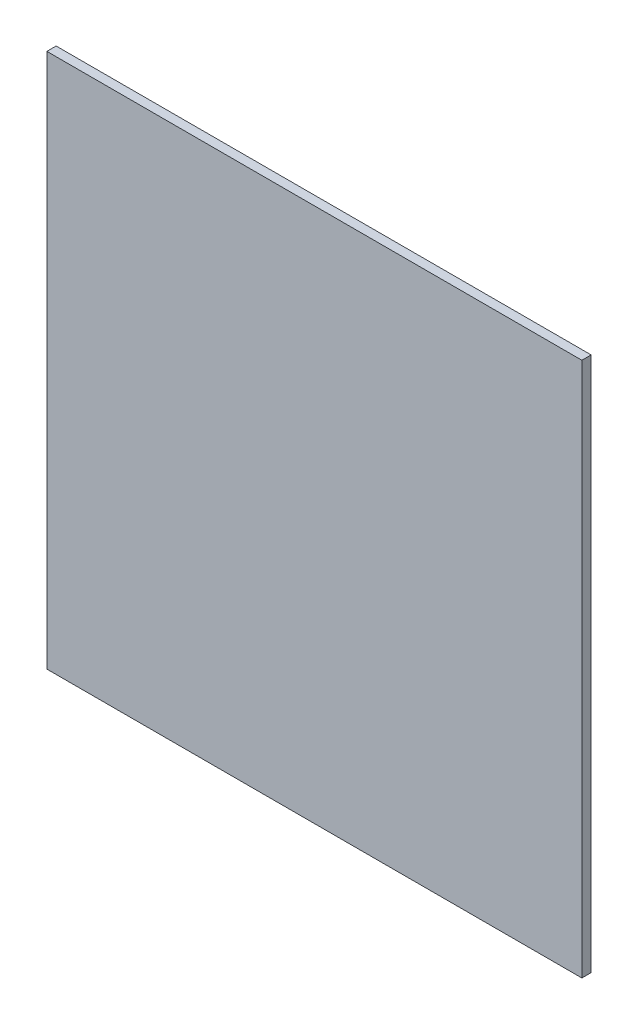
from build123d import *

# Parameters (mm, degrees)
SKETCH1_W           = 1100
SKETCH1_H           = 1100
BOSS_EXTRUDE1_DEPTH = 19.05


with BuildPart() as part:
    # Sketch1 → Boss-Extrude1 (new body)
    with BuildSketch(Plane.XY):
        Rectangle(SKETCH1_W, SKETCH1_H)
    extrude(amount=BOSS_EXTRUDE1_DEPTH)


solid = part.part
